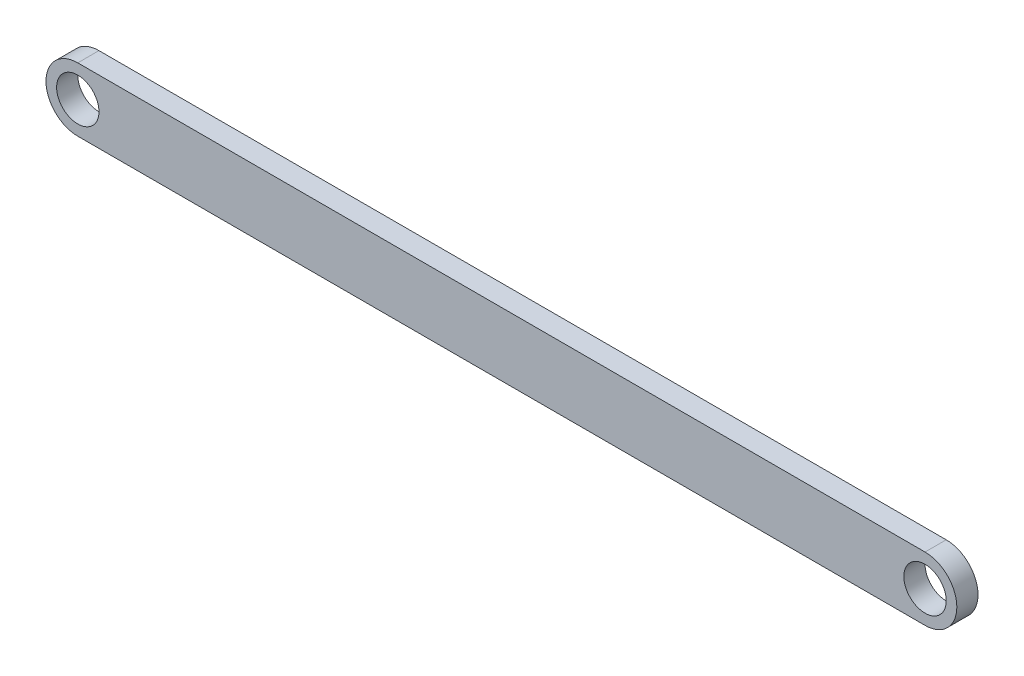
from build123d import *

# Parameters (mm, degrees)
SKETCH_1_R      = 2
EXTRUDE_1_DEPTH = 2


with BuildPart() as part:
    # 草图1 → 凸台-拉伸1 (new body)
    with BuildSketch(Plane.XY):
        with BuildLine():
            Line((-43.692939909, -3), (36.307060091, -3))
            ThreePointArc((36.307060091, -3), (39.307060091, 0), (36.307060091, 3))
            Line((36.307060091, 3), (-43.692939909, 3))
            ThreePointArc((-43.692939909, 3), (-46.692939909, 0), (-43.692939909, -3))
        make_face()
        with Locations((36.307060091, 0)):
            Circle(SKETCH_1_R, mode=Mode.SUBTRACT)
        with Locations((-43.692939909, 0)):
            Circle(SKETCH_1_R, mode=Mode.SUBTRACT)
    extrude(amount=EXTRUDE_1_DEPTH)


solid = part.part
